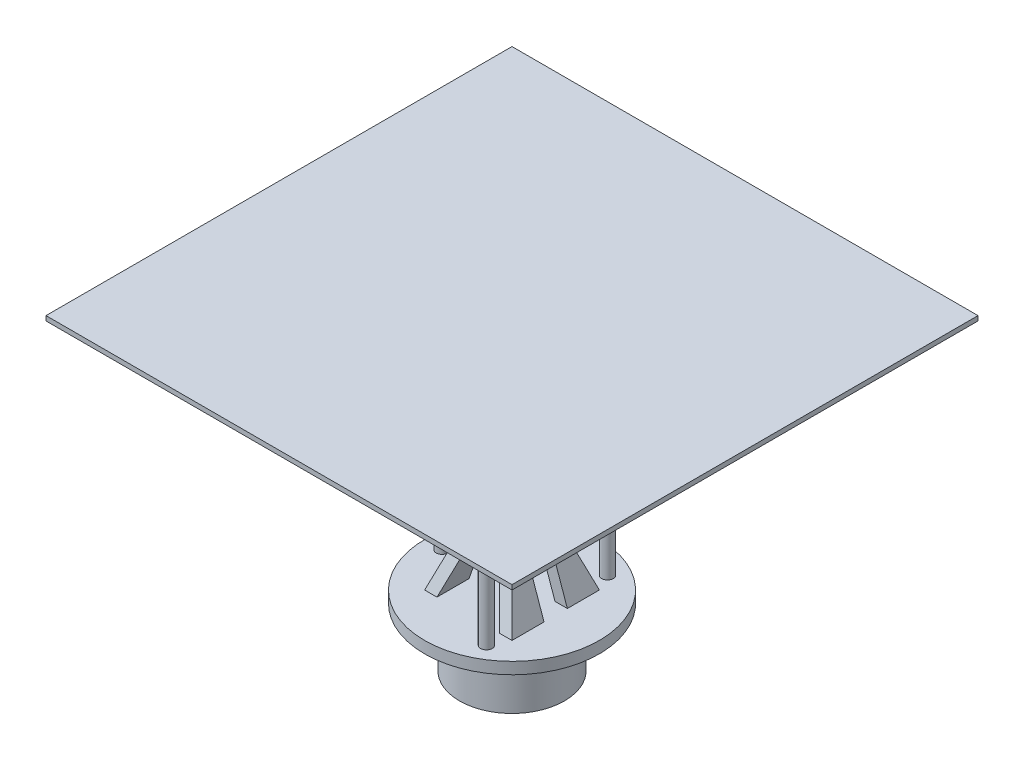
from build123d import *

# Parameters (mm, degrees)
SKETCH1_R               = 75
BOSS_EXTRUDE1_DEPTH     = 10
SKETCH2_R               = 45
SKETCH2_R_2             = 40
BOSS_EXTRUDE2_DEPTH     = 50
SKETCH5_W               = 75
SKETCH5_H               = 75
BOSS_EXTRUDE3_DEPTH     = 50
CUT_EXTRUDE2_DEPTH      = 103
CUT_EXTRUDE3_DEPTH      = 103
CUT_EXTRUDE3_DEPTH_BACK = 103
CUT_EXTRUDE4_DEPTH      = 103
CUT_EXTRUDE4_DEPTH_BACK = 103
SKETCH9_W               = 20
SKETCH9_H               = 50
SKETCH10_R              = 5
CUT_EXTRUDE5_DEPTH      = 103
SKETCH11_R              = 5
SKETCH13_W              = 400
SKETCH13_H              = 400
BOSS_EXTRUDE4_DEPTH     = 4


with BuildPart() as part:
    # Sketch1 → Boss-Extrude1 (new body)
    with BuildSketch(Plane(origin=(0, 0, 0), x_dir=(1, 0, 0), z_dir=(0, 1, 0))):
        Circle(SKETCH1_R)
    extrude(amount=BOSS_EXTRUDE1_DEPTH)

    # Sketch2 → Boss-Extrude2 (add)
    with BuildSketch(Plane.XZ):
        Circle(SKETCH2_R)
        Circle(SKETCH2_R_2, mode=Mode.SUBTRACT)
    extrude(amount=BOSS_EXTRUDE2_DEPTH)

    # Sketch5 → Boss-Extrude3 (add)
    with BuildSketch(Plane(origin=(0, 10, 0), x_dir=(1, 0, 0), z_dir=(0, 1, 0))):
        Rectangle(SKETCH5_W, SKETCH5_H)
    extrude(amount=BOSS_EXTRUDE3_DEPTH)

    # Sketch6 → Cut-Extrude2 (cut)
    with BuildSketch(Plane.XY.offset(37.5)):
        Polygon((20, 60), (37.5, 10), (43.069722315, 10), (43.069722315, 63.034625831), (-42.678571429, 63.034625831), (-42.678571429, 10), (-37.5, 10), (-20, 60), align=None)
        Polygon((-12.90518995, 50), (-26.90518995, 10), (26.90518995, 10), (12.90518995, 50), align=None)
    extrude(amount=-CUT_EXTRUDE2_DEPTH, mode=Mode.SUBTRACT)

    # Sketch7 → Cut-Extrude3 (cut, two sides: drawn at the far end of the back side and taken through both)
    with BuildSketch(Plane(origin=(0, 0, 0), x_dir=(0, 0, -1), z_dir=(1, 0, 0)).offset(-CUT_EXTRUDE3_DEPTH_BACK)):
        Polygon((20, 60), (-20, 60), (-37.5, 10), (-47.69302584, 10), (-47.69302584, 63.764621125), (47.449694076, 63.764621125), (47.449694076, 10), (37.5, 10), align=None)
    extrude(amount=CUT_EXTRUDE3_DEPTH + CUT_EXTRUDE3_DEPTH_BACK, mode=Mode.SUBTRACT)

    # Sketch9 → Cut-Extrude4 (cut, two sides: drawn at the far end of the back side and taken through both)
    with BuildSketch(Plane(origin=(0, 0, 0), x_dir=(0, 0, -1), z_dir=(1, 0, 0)).offset(-CUT_EXTRUDE4_DEPTH_BACK)):
        with Locations((0, 35)):
            Rectangle(SKETCH9_W, SKETCH9_H)
    extrude(amount=CUT_EXTRUDE4_DEPTH + CUT_EXTRUDE4_DEPTH_BACK, mode=Mode.SUBTRACT)

    # Sketch10 → Cut-Extrude5 (cut)
    with BuildSketch(Plane(origin=(0, 10, 0), x_dir=(1, 0, 0), z_dir=(0, 1, 0))):
        Circle(SKETCH10_R)
    extrude(amount=-CUT_EXTRUDE5_DEPTH, mode=Mode.SUBTRACT)

    # Sweep1: sweep along a curve in space
    with BuildLine() as sweep1_path:
        Line((-60, 10, 0), (-60, 210, 0))
    # Sketch11 → Sweep1 (sweep)
    with BuildSketch(Plane(origin=(0, 10, 0), x_dir=(1, 0, 0), z_dir=(0, 1, 0))):
        with Locations((-60, 0)):
            Circle(SKETCH11_R)
        with Locations((30, 51.961524227)):
            Circle(SKETCH11_R)
        with Locations((30, -51.961524227)):
            Circle(SKETCH11_R)
    sweep(path=sweep1_path.line)

    # Sketch13 → Boss-Extrude4 (add)
    with BuildSketch(Plane(origin=(0, 210, 0), x_dir=(1, 0, 0), z_dir=(0, 1, 0))):
        Rectangle(SKETCH13_W, SKETCH13_H)
    extrude(amount=BOSS_EXTRUDE4_DEPTH)

    # Sketch17 → Revolve2 (revolve)
    with BuildSketch(Plane(origin=(0, 0, 0), x_dir=(0, 0, -1), z_dir=(1, 0, 0))):
        Polygon((10, 55), (10, 70), (5, 70), (3.237517532, 60.004465223), (-3.237517532, 60.004465223), (-5, 70), (-10, 70), (-10, 55), align=None)
    revolve(axis=Axis((0, 55, -10), (0, 0, 1)))


solid = part.part
